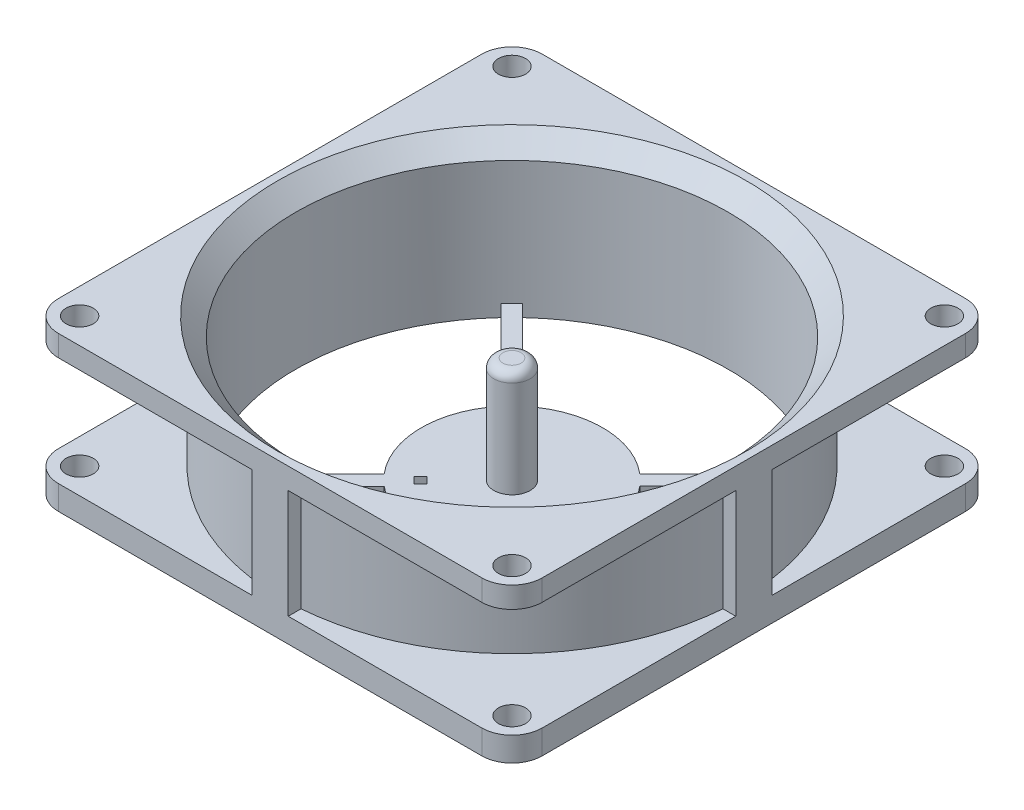
from build123d import *

# Parameters (mm, degrees)
SKETCH1_W            = 80
SKETCH1_H            = 80
BOSS_EXTRUDE1_DEPTH  = 25.5
SKETCH2_R            = 35.75
CUT_EXTRUDE2_DEPTH   = 28
BOSS_EXTRUDE2_DEPTH  = 2
CIRPATTERN2_COUNT    = 4
SKETCH5_R            = 15
BOSS_EXTRUDE3_DEPTH  = 2
SKETCH6_R            = 3
BOSS_EXTRUDE4_DEPTH  = 17.5
FILLET1_R            = 1.5
SKETCH7_R            = 70
SKETCH7_R_2          = 38
CUT_EXTRUDE4_DEPTH   = 18
FILLET2_R            = 5
BOSS_EXTRUDE5_DEPTH  = 20
CIRPATTERN3_COUNT    = 4
SKETCH9_R            = 2.25
CUT_EXTRUDE5_DEPTH   = 37
LPATTERN1_COUNT      = 2
LPATTERN1_PITCH      = 71.5
LPATTERN1_COUNT_DIR2 = 2
LPATTERN1_PITCH_DIR2 = 71.5
CHAMFER2_SIZE        = 3
CUT_EXTRUDE6_DEPTH   = 1
CUT_EXTRUDE7_DEPTH   = 7


with BuildPart() as part:
    # Sketch1 → Boss-Extrude1 (new body)
    with BuildSketch(Plane(origin=(0, 0, 0), x_dir=(1, 0, 0), z_dir=(0, 1, 0))):
        Rectangle(SKETCH1_W, SKETCH1_H)
    extrude(amount=BOSS_EXTRUDE1_DEPTH)

    # Sketch2 → Cut-Extrude2 (cut)
    with BuildSketch(Plane(origin=(0, 25.5, 0), x_dir=(1, 0, 0), z_dir=(0, 1, 0))):
        Circle(SKETCH2_R)
    extrude(amount=-CUT_EXTRUDE2_DEPTH, mode=Mode.SUBTRACT)

    # Sketch4 → Boss-Extrude2 (add)
    with BuildSketch(Plane.XZ):
        with BuildLine():
            Line((-1.75, 0), (0, 1.785533906))
            Line((0, 1.785533906), (-24.370530875, 26.156064781))
            ThreePointArc((-24.370530875, 26.156064781), (-25.270176953, 25.287954776), (-26.138919431, 24.388919431))
            Line((-26.138919431, 24.388919431), (-1.75, 0))
        make_face()
    boss_extrude2 = extrude(amount=-BOSS_EXTRUDE2_DEPTH)

    # CirPattern2: Boss-Extrude2 ×4 about axis
    cirpattern2_axis = Axis((0, 0, 0), (0, 1, 0))
    for i in range(1, CIRPATTERN2_COUNT):
        add(boss_extrude2.rotate(cirpattern2_axis, i * 360 / CIRPATTERN2_COUNT))

    # Sketch5 → Boss-Extrude3 (add)
    with BuildSketch(Plane.XZ):
        Circle(SKETCH5_R)
    extrude(amount=-BOSS_EXTRUDE3_DEPTH)

    # Sketch6 → Boss-Extrude4 (add)
    with BuildSketch(Plane(origin=(0, 2, 0), x_dir=(1, 0, 0), z_dir=(0, 1, 0))):
        Circle(SKETCH6_R)
    extrude(amount=BOSS_EXTRUDE4_DEPTH)

    # Fillet1
    fillet1_edges = [part.edges().sort_by_distance(p)[0] for p in [
        (-3, 19.5, 0),
    ]]
    fillet(fillet1_edges, radius=FILLET1_R)

    # Sketch7 → Cut-Extrude4 (cut)
    with BuildSketch(Plane.XZ.offset(-4)):
        Circle(SKETCH7_R)
        Circle(SKETCH7_R_2, mode=Mode.SUBTRACT)
    extrude(amount=-CUT_EXTRUDE4_DEPTH, mode=Mode.SUBTRACT)

    # Fillet2
    fillet2_edges = [part.edges().sort_by_distance(p)[0] for p in [
        (-40, 2, -40),
        (40, 2, -40),
        (40, 2, 40),
        (-40, 2, 40),
        (-40, 23.75, -40),
        (40, 23.75, -40),
        (40, 23.75, 40),
        (-40, 23.75, 40),
    ]]
    fillet(fillet2_edges, radius=FILLET2_R)

    # Sketch8 → Boss-Extrude5 (add)
    with BuildSketch(Plane.XZ.offset(-4)):
        with BuildLine():
            Line((-3, 40), (3, 40))
            Line((3, 40), (3, 35.623903492))
            ThreePointArc((3, 35.623903492), (0, 35.75), (-3, 35.623903492))
            Line((-3, 35.623903492), (-3, 40))
        make_face()
    boss_extrude5 = extrude(amount=-BOSS_EXTRUDE5_DEPTH)

    # CirPattern3: Boss-Extrude5 ×4 about axis
    cirpattern3_axis = Axis((0, 0, 0), (0, 1, 0))
    for i in range(1, CIRPATTERN3_COUNT):
        add(boss_extrude5.rotate(cirpattern3_axis, i * 360 / CIRPATTERN3_COUNT))

    # Sketch9 → Cut-Extrude5 (cut)
    with BuildSketch(Plane(origin=(0, 25.5, 0), x_dir=(-1, 0, 0), z_dir=(0, 1, 0))):
        with Locations((35.75, -35.75)):
            Circle(SKETCH9_R)
    cut_extrude5 = extrude(amount=-CUT_EXTRUDE5_DEPTH, mode=Mode.SUBTRACT)

    # LPattern1: Cut-Extrude5 2 × 2
    with Locations(*[(i * LPATTERN1_PITCH, 0, j * LPATTERN1_PITCH_DIR2) for i in range(LPATTERN1_COUNT) for j in range(LPATTERN1_COUNT_DIR2) if (i, j) != (0, 0)]):
        add(cut_extrude5, mode=Mode.SUBTRACT)

    # Chamfer2
    chamfer2_edges = [part.edges().sort_by_distance(p)[0] for p in [
        (-35.75, 25.5, 0),
    ]]
    chamfer(chamfer2_edges, length=CHAMFER2_SIZE)

    # Sketch11 → Cut-Extrude6 (cut)
    with BuildSketch(Plane.XZ):
        Polygon((-28.863216429, 27.820323211), (-7.554875149, 6.51198193), (-6.494214977, 7.572642102), (-28.241896086, 29.320323211), (-40, 29.320323211), (-40, 27.820323211), align=None)
    extrude(amount=-CUT_EXTRUDE6_DEPTH, mode=Mode.SUBTRACT)

    # Sketch12 → Cut-Extrude7 (cut)
    with BuildSketch(Plane.XZ.offset(-1)):
        Polygon((-6.494214977, 7.572642102), (-7.554875149, 8.633302273), (-8.61553532, 7.572642102), (-7.554875149, 6.51198193), align=None)
    extrude(amount=-CUT_EXTRUDE7_DEPTH, mode=Mode.SUBTRACT)


solid = part.part
